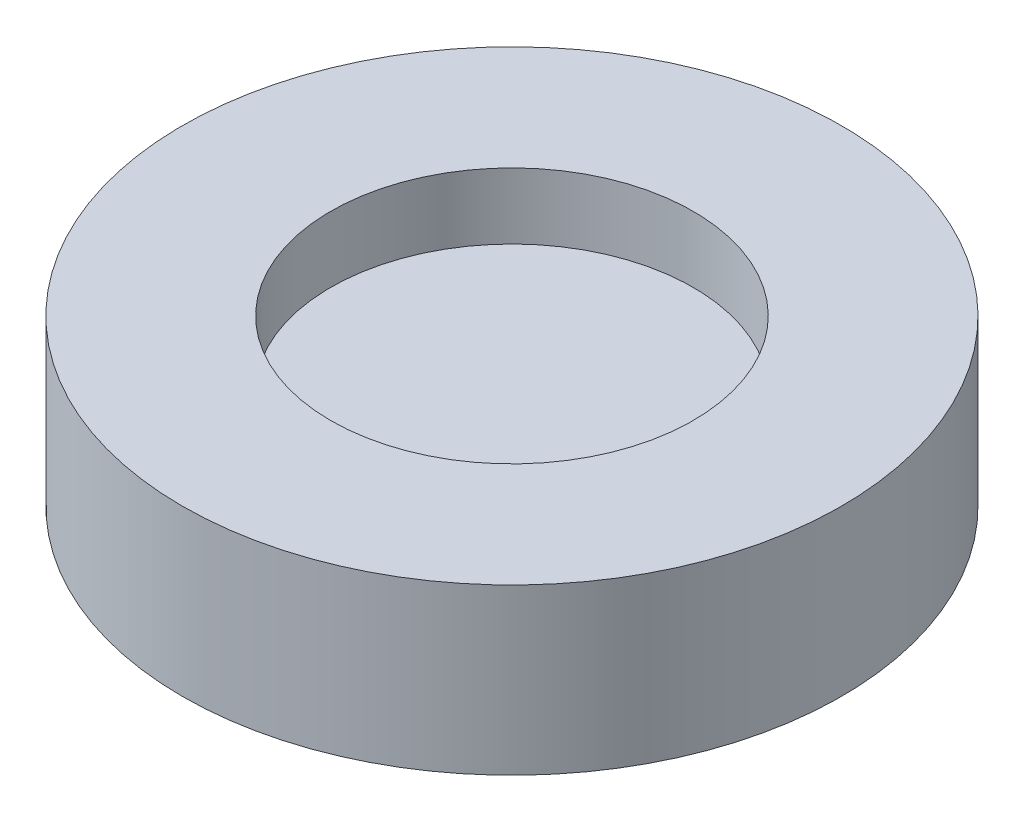
from build123d import *

# Parameters (mm, degrees)
SKETCH1_R           = 10
BOSS_EXTRUDE1_DEPTH = 5
SKETCH2_R           = 5.5
CUT_EXTRUDE1_DEPTH  = 2
SKETCH3_R           = 1.25
CUT_EXTRUDE2_DEPTH  = 2.5
FILLET1_R           = 1


with BuildPart() as part:
    # Sketch1 → Boss-Extrude1 (new body)
    with BuildSketch(Plane(origin=(0, 0, 0), x_dir=(1, 0, 0), z_dir=(0, 1, 0))):
        Circle(SKETCH1_R)
    extrude(amount=BOSS_EXTRUDE1_DEPTH)

    # Sketch2 → Cut-Extrude1 (cut)
    with BuildSketch(Plane(origin=(0, 5, 0), x_dir=(1, 0, 0), z_dir=(0, 1, 0))):
        Circle(SKETCH2_R)
    extrude(amount=-CUT_EXTRUDE1_DEPTH, mode=Mode.SUBTRACT)

    # Sketch3 → Cut-Extrude2 (cut)
    with BuildSketch(Plane.XZ):
        Circle(SKETCH3_R)
    extrude(amount=-CUT_EXTRUDE2_DEPTH, mode=Mode.SUBTRACT)

    # Fillet1
    fillet1_edges = [part.edges().sort_by_distance(p)[0] for p in [
        (-1.25, 2.5, 0),
    ]]
    fillet(fillet1_edges, radius=FILLET1_R)


solid = part.part
